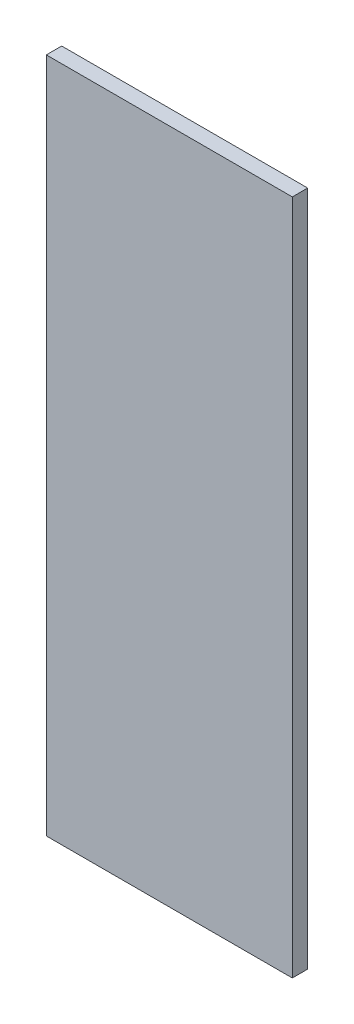
from build123d import *

# Parameters (mm, degrees)
SKETCH1_W           = 50.8
SKETCH1_H           = 139.7
BOSS_EXTRUDE1_DEPTH = 3.175


with BuildPart() as part:
    # Sketch1 → Boss-Extrude1 (new body)
    with BuildSketch(Plane.XY):
        with Locations((25.4, 69.85)):
            Rectangle(SKETCH1_W, SKETCH1_H)
    extrude(amount=BOSS_EXTRUDE1_DEPTH)


solid = part.part
